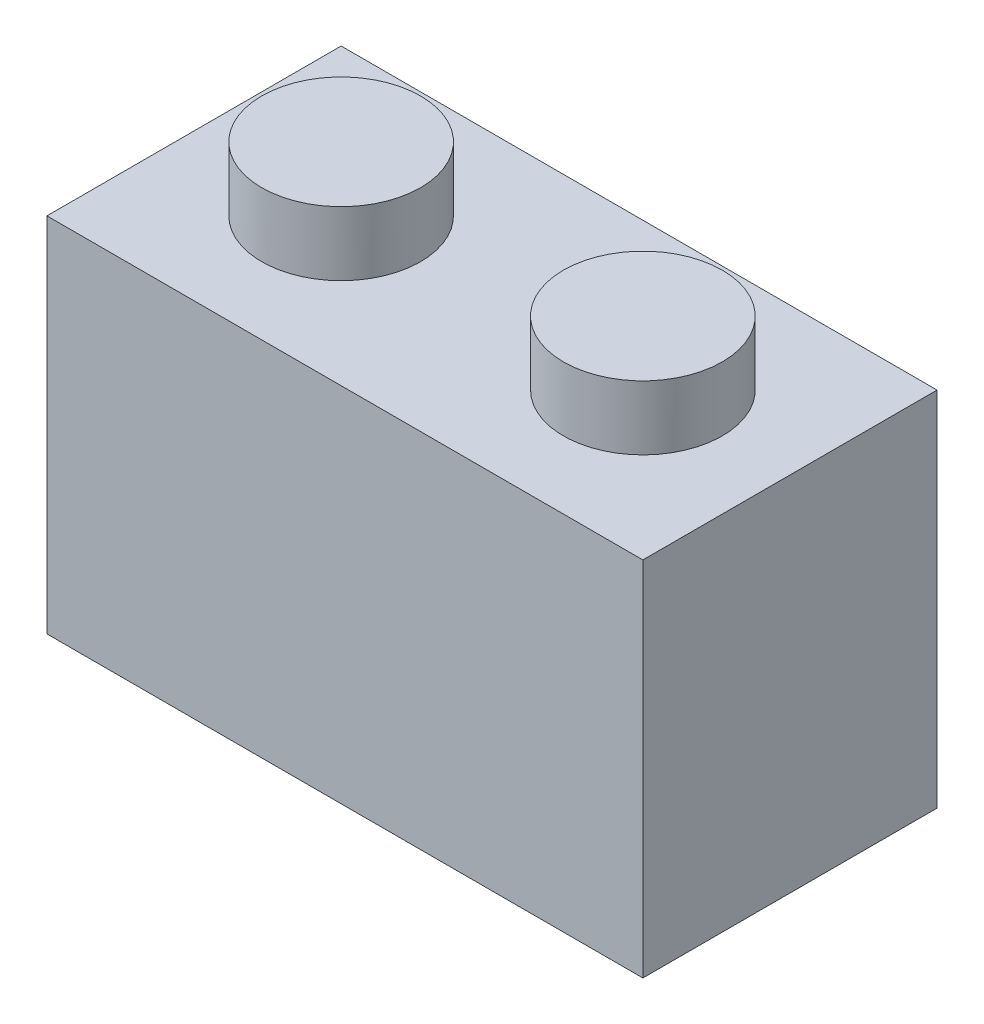
from build123d import *

# Parameters (mm, degrees)
SKETCH_1_W          = 15.8
SKETCH_1_H          = 7.8
EXTRUDE_2_DEPTH     = 9.6
SKETCH_2_R          = 2.106660513
EXTRUDE_3_DEPTH     = 1.7
SKETCH_3_R          = 2.5
CUT_EXTRUDE_1_DEPTH = 1.8


with BuildPart() as part:
    # Эскиз1 → Бобышка-Вытянуть2 (new body)
    with BuildSketch(Plane(origin=(0, 0, 0), x_dir=(1, 0, 0), z_dir=(0, 1, 0))):
        with Locations((7.9, 3.9)):
            Rectangle(SKETCH_1_W, SKETCH_1_H)
    extrude(amount=EXTRUDE_2_DEPTH)

    # Эскиз2 → Бобышка-Вытянуть3 (add)
    with BuildSketch(Plane(origin=(0, 9.6, 0), x_dir=(1, 0, 0), z_dir=(0, 1, 0))):
        with Locations((3.9, 3.9)):
            Circle(SKETCH_2_R)
        with Locations((11.9, 3.9)):
            Circle(SKETCH_2_R)
    extrude(amount=EXTRUDE_3_DEPTH)

    # Эскиз3 → Вырез-Вытянуть1 (cut)
    with BuildSketch(Plane.XZ):
        with Locations((11.9, -3.9)):
            Circle(SKETCH_3_R)
        with Locations((3.9, -3.9)):
            Circle(SKETCH_3_R)
    extrude(amount=-CUT_EXTRUDE_1_DEPTH, mode=Mode.SUBTRACT)


solid = part.part
